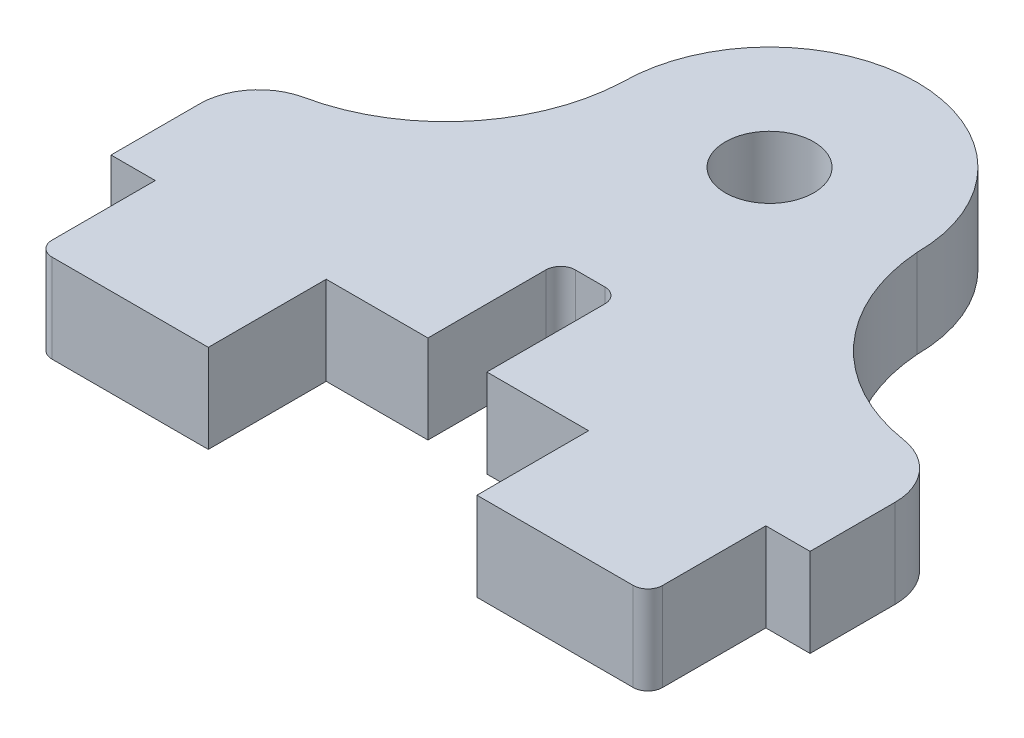
from build123d import *

# Parameters (mm, degrees)
BOSS_EXTRUDE1_DEPTH = 3
SKETCH3_R           = 1.5
CUT_EXTRUDE1_DEPTH  = 3
FILLET1_R           = 2
FILLET2_R           = 0.5


with BuildPart() as part:
    # Sketch2 → Boss-Extrude1 (new body)
    with BuildSketch(Plane(origin=(0, 0, 0), x_dir=(1, 0, 0), z_dir=(0, 1, 0))):
        with BuildLine():
            Line((-11.531388224, -10.806413351), (-10.031388224, -10.806413351))
            Line((-10.031388224, -10.806413351), (-10.031388224, -14.806413351))
            Line((-10.031388224, -14.806413351), (-4.231388224, -14.806413351))
            Line((-4.231388224, -14.806413351), (-4.231388224, -10.806413351))
            Line((-4.231388224, -10.806413351), (-0.781388224, -10.806413351))
            Line((-0.781388224, -10.806413351), (-0.781388224, -6.306413351))
            Line((-0.781388224, -6.306413351), (1.218611776, -6.306413351))
            Line((1.218611776, -6.306413351), (1.218611776, -10.806413351))
            Line((1.218611776, -10.806413351), (4.668611776, -10.806413351))
            Line((4.668611776, -10.806413351), (4.668611776, -14.59443044))
            Line((4.668611776, -14.59443044), (10.468611776, -14.59443044))
            Line((10.468611776, -14.59443044), (10.468611776, -10.59443044))
            Line((10.468611776, -10.59443044), (11.968611776, -10.59443044))
            Line((11.968611776, -10.59443044), (11.968611776, -5.761851858))
            ThreePointArc((11.968611776, -5.761851858), (7.254363967, -4.368466387), (5, 0))
            ThreePointArc((5, 0), (0, 5), (-5, 0))
            ThreePointArc((-5, 0), (-7.028472422, -4.339612176), (-11.531388224, -5.973834769))
            Line((-11.531388224, -5.973834769), (-11.531388224, -10.806413351))
        make_face()
    extrude(amount=BOSS_EXTRUDE1_DEPTH)

    # Sketch3 → Cut-Extrude1 (cut)
    with BuildSketch(Plane(origin=(0, 3, 0), x_dir=(1, 0, 0), z_dir=(0, 1, 0))):
        Circle(SKETCH3_R)
    extrude(amount=-CUT_EXTRUDE1_DEPTH, mode=Mode.SUBTRACT)

    # Fillet1
    fillet1_edges = [part.edges().sort_by_distance(p)[0] for p in [
        (11.968611776, 1.5, 5.761851858),
        (-11.531388224, 1.5, 5.973834769),
    ]]
    fillet(fillet1_edges, radius=FILLET1_R)

    # Fillet2
    fillet2_edges = [part.edges().sort_by_distance(p)[0] for p in [
        (10.468611776, 1.5, 14.59443044),
        (1.218611776, 1.5, 6.306413351),
        (-0.781388224, 1.5, 6.306413351),
        (-10.031388224, 1.5, 14.806413351),
    ]]
    fillet(fillet2_edges, radius=FILLET2_R)


solid = part.part
